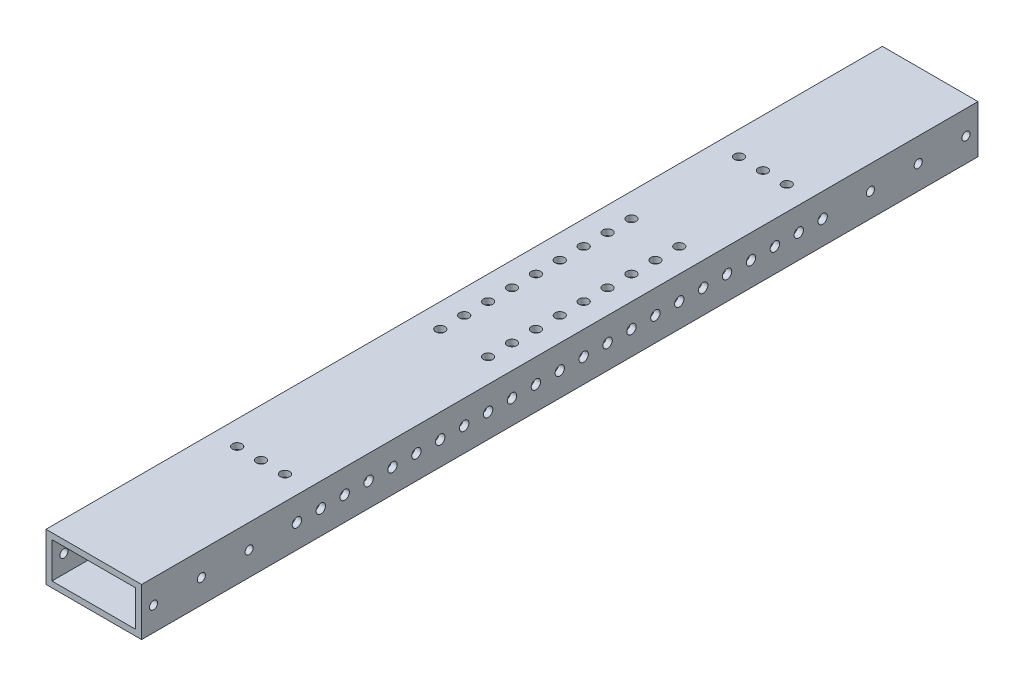
from build123d import *

# Parameters (mm, degrees)
SKETCH1_W           = 50.8
SKETCH1_H           = 25.4
SKETCH1_W_2         = 44.45
SKETCH1_H_2         = 19.05
BOSS_EXTRUDE1_DEPTH = 222.25
SKETCH3_R           = 2.15265
SKETCH3_R_2         = 2.159
CUT_EXTRUDE2_DEPTH  = 51.8
SKETCH4_R           = 2.4892
CUT_EXTRUDE3_DEPTH  = 51.8
SKETCH5_R           = 2.4892
CUT_EXTRUDE4_DEPTH  = 26.4


with BuildPart() as part:
    # Sketch1 → Boss-Extrude1 (new body, symmetric)
    with BuildSketch(Plane.XY):
        Rectangle(SKETCH1_W, SKETCH1_H)
        Rectangle(SKETCH1_W_2, SKETCH1_H_2, mode=Mode.SUBTRACT)
    extrude(amount=BOSS_EXTRUDE1_DEPTH, both=True)

    # Sketch3 → Cut-Extrude2 (cut, through all)
    with BuildSketch(Plane(origin=(25.4, 0, 0), x_dir=(0, 0, -1), z_dir=(1, 0, 0))):
        with Locations((-215.9, 0)):
            Circle(SKETCH3_R)
        with Locations((-190.5, 0)):
            Circle(SKETCH3_R)
        with Locations((-165.1, 0)):
            Circle(SKETCH3_R)
        with Locations((215.9, 0)):
            Circle(SKETCH3_R_2)
        with Locations((190.5, 0)):
            Circle(SKETCH3_R_2)
        with Locations((165.1, 0)):
            Circle(SKETCH3_R_2)
    extrude(amount=-CUT_EXTRUDE2_DEPTH, mode=Mode.SUBTRACT)

    # Sketch4 → Cut-Extrude3 (cut, through all)
    with BuildSketch(Plane(origin=(25.4, 0, 0), x_dir=(0, 0, -1), z_dir=(1, 0, 0))):
        with Locations((-139.7, 0)):
            Circle(SKETCH4_R)
        with Locations((-127, 0)):
            Circle(SKETCH4_R)
        with Locations((-114.3, 0)):
            Circle(SKETCH4_R)
        with Locations((-101.6, 0)):
            Circle(SKETCH4_R)
        with Locations((-88.9, 0)):
            Circle(SKETCH4_R)
        with Locations((-76.2, 0)):
            Circle(SKETCH4_R)
        with Locations((-63.5, 0)):
            Circle(SKETCH4_R)
        with Locations((-50.8, 0)):
            Circle(SKETCH4_R)
        with Locations((-38.1, 0)):
            Circle(SKETCH4_R)
        with Locations((-25.4, 0)):
            Circle(SKETCH4_R)
        with Locations((-12.7, 0)):
            Circle(SKETCH4_R)
        Circle(SKETCH4_R)
        with Locations((12.7, 0)):
            Circle(SKETCH4_R)
        with Locations((25.4, 0)):
            Circle(SKETCH4_R)
        with Locations((38.1, 0)):
            Circle(SKETCH4_R)
        with Locations((50.8, 0)):
            Circle(SKETCH4_R)
        with Locations((63.5, 0)):
            Circle(SKETCH4_R)
        with Locations((76.2, 0)):
            Circle(SKETCH4_R)
        with Locations((88.9, 0)):
            Circle(SKETCH4_R)
        with Locations((101.6, 0)):
            Circle(SKETCH4_R)
        with Locations((114.3, 0)):
            Circle(SKETCH4_R)
        with Locations((127, 0)):
            Circle(SKETCH4_R)
        with Locations((139.7, 0)):
            Circle(SKETCH4_R)
    extrude(amount=-CUT_EXTRUDE3_DEPTH, mode=Mode.SUBTRACT)

    # Sketch5 → Cut-Extrude4 (cut, through all)
    with BuildSketch(Plane.XZ.offset(12.7)):
        with Locations((-12.7, 133.35)):
            Circle(SKETCH5_R)
        with Locations((0, 133.35)):
            Circle(SKETCH5_R)
        with Locations((12.7, 133.35)):
            Circle(SKETCH5_R)
        with Locations((12.7, -133.35)):
            Circle(SKETCH5_R)
        with Locations((0, -133.35)):
            Circle(SKETCH5_R)
        with Locations((-12.7, -133.35)):
            Circle(SKETCH5_R)
        with Locations((-12.7, 25.4)):
            Circle(SKETCH5_R)
        with Locations((12.7, 25.4)):
            Circle(SKETCH5_R)
        with Locations((12.7, 12.7)):
            Circle(SKETCH5_R)
        with Locations((-12.7, 12.7)):
            Circle(SKETCH5_R)
        with Locations((12.7, 0)):
            Circle(SKETCH5_R)
        with Locations((-12.7, 0)):
            Circle(SKETCH5_R)
        with Locations((12.7, -12.7)):
            Circle(SKETCH5_R)
        with Locations((-12.7, -12.7)):
            Circle(SKETCH5_R)
        with Locations((12.7, -25.4)):
            Circle(SKETCH5_R)
        with Locations((-12.7, -25.4)):
            Circle(SKETCH5_R)
        with Locations((12.7, -38.1)):
            Circle(SKETCH5_R)
        with Locations((-12.7, -38.1)):
            Circle(SKETCH5_R)
        with Locations((12.7, -50.8)):
            Circle(SKETCH5_R)
        with Locations((-12.7, -50.8)):
            Circle(SKETCH5_R)
        with Locations((12.7, -63.5)):
            Circle(SKETCH5_R)
        with Locations((-12.7, -63.5)):
            Circle(SKETCH5_R)
        with Locations((12.7, -76.2)):
            Circle(SKETCH5_R)
        with Locations((-12.7, -76.2)):
            Circle(SKETCH5_R)
    extrude(amount=-CUT_EXTRUDE4_DEPTH, mode=Mode.SUBTRACT)


solid = part.part
